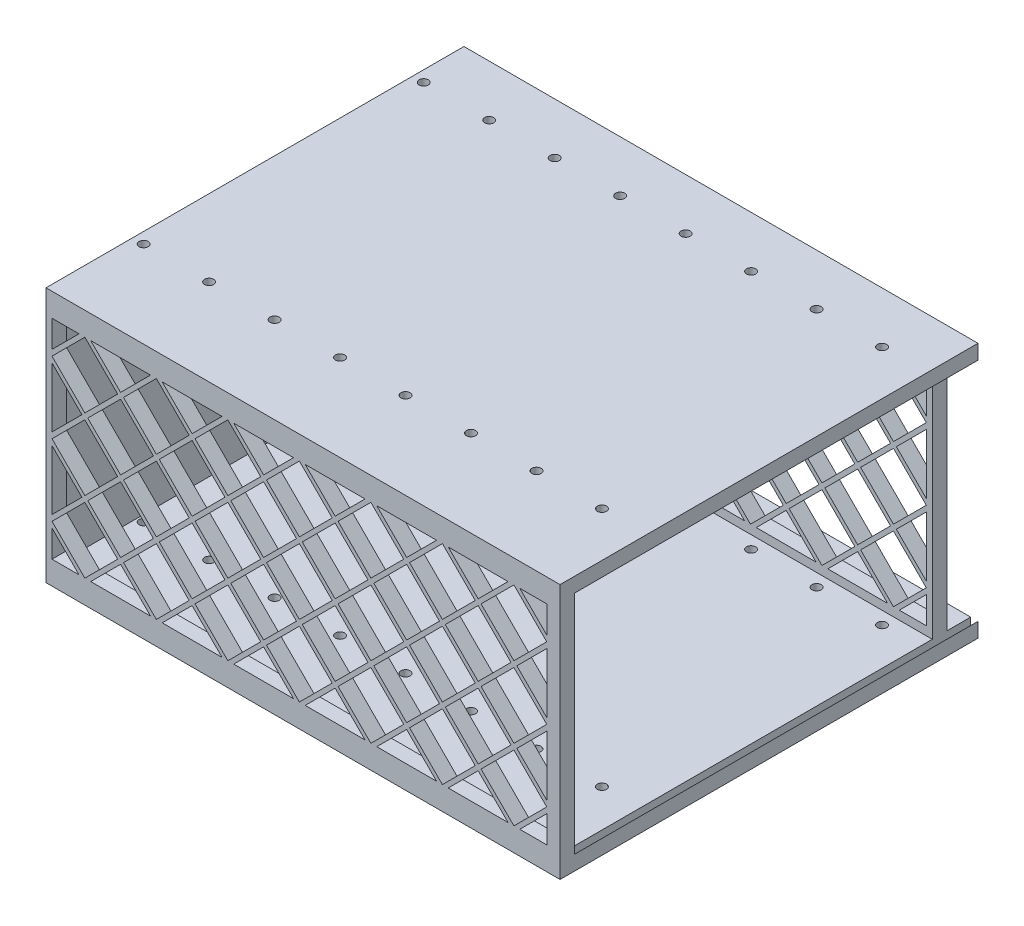
from build123d import *

# Parameters (mm, degrees)
SKETCH1_W           = 140.589
SKETCH1_H           = 114.3
BOSS_EXTRUDE1_DEPTH = 69.85
SKETCH4_W           = 6.5
SKETCH4_H           = 61.85
CUT_EXTRUDE2_DEPTH  = 141.589
SKETCH3_W           = 99.8
SKETCH3_H           = 61.85
CUT_EXTRUDE3_DEPTH  = 139.389
SKETCH2_R           = 1.25
CUT_EXTRUDE1_DEPTH  = 4
CUT_EXTRUDE4_DEPTH  = 110.3
CUT_EXTRUDE5_DEPTH  = 4


with BuildPart() as part:
    # Sketch1 → Boss-Extrude1 (new body)
    with BuildSketch(Plane(origin=(0, 0, 0), x_dir=(1, 0, 0), z_dir=(0, 1, 0))):
        with Locations((70.2945, 57.15)):
            Rectangle(SKETCH1_W, SKETCH1_H)
    extrude(amount=BOSS_EXTRUDE1_DEPTH)

    # Sketch4 → Cut-Extrude2 (cut, through all)
    with BuildSketch(Plane(origin=(140.589, 0, 0), x_dir=(0, 0, -1), z_dir=(1, 0, 0))):
        with Locations((111.05, 34.925)):
            Rectangle(SKETCH4_W, SKETCH4_H)
    extrude(amount=-CUT_EXTRUDE2_DEPTH, mode=Mode.SUBTRACT)

    # Sketch3 → Cut-Extrude3 (cut)
    with BuildSketch(Plane(origin=(140.589, 0, 0), x_dir=(0, 0, -1), z_dir=(1, 0, 0))):
        with Locations((53.9, 34.925)):
            Rectangle(SKETCH3_W, SKETCH3_H)
    extrude(amount=-CUT_EXTRUDE3_DEPTH, mode=Mode.SUBTRACT)

    # Sketch2 → Cut-Extrude1 (cut)
    with BuildSketch(Plane(origin=(0, 69.85, 0), x_dir=(1, 0, 0), z_dir=(0, 1, 0))):
        with Locations((3, 100.3)):
            Circle(SKETCH2_R)
        with Locations((3, 23.7)):
            Circle(SKETCH2_R)
        with Locations((20.907, 100.3)):
            Circle(SKETCH2_R)
        with Locations((20.907, 23.7)):
            Circle(SKETCH2_R)
        with Locations((38.814, 100.3)):
            Circle(SKETCH2_R)
        with Locations((38.814, 23.7)):
            Circle(SKETCH2_R)
        with Locations((56.721, 100.3)):
            Circle(SKETCH2_R)
        with Locations((56.721, 23.7)):
            Circle(SKETCH2_R)
        with Locations((74.628, 100.3)):
            Circle(SKETCH2_R)
        with Locations((74.628, 23.7)):
            Circle(SKETCH2_R)
        with Locations((92.535, 100.3)):
            Circle(SKETCH2_R)
        with Locations((92.535, 23.7)):
            Circle(SKETCH2_R)
        with Locations((110.442, 100.3)):
            Circle(SKETCH2_R)
        with Locations((110.442, 23.7)):
            Circle(SKETCH2_R)
        with Locations((128.349, 100.3)):
            Circle(SKETCH2_R)
        with Locations((128.349, 23.7)):
            Circle(SKETCH2_R)
    cut_extrude1 = extrude(amount=-CUT_EXTRUDE1_DEPTH, mode=Mode.SUBTRACT)

    # Mirror1: Cut-Extrude1 across plane
    add(cut_extrude1.mirror(Plane.ZX.offset(34.925)), mode=Mode.SUBTRACT)

    # Sketch5 → Cut-Extrude4 (cut)
    with BuildSketch(Plane(origin=(0, 0, -114.3), x_dir=(-1, 0, 0), z_dir=(0, 0, -1))):
        Polygon((-138.589, 67.85), (-138.589, 2), (-140.589, 4), (-140.589, 65.85), align=None)
    extrude(amount=-CUT_EXTRUDE4_DEPTH, mode=Mode.SUBTRACT)

    # Sketch6 → Cut-Extrude5 (cut)
    with BuildSketch(Plane(origin=(0, 0, -107.8), x_dir=(-1, 0, 0), z_dir=(0, 0, -1))):
        Polygon((-136.948756121, 54.483), (-127.9685, 45.502743879), (-118.988243879, 54.483), (-127.9685, 63.463256121), align=None)
        Polygon((-108.4105, 63.463256121), (-117.390756121, 54.483), (-108.4105, 45.502743879), (-99.430243879, 54.483), align=None)
        Polygon((-88.8525, 63.463256121), (-97.832756121, 54.483), (-88.8525, 45.502743879), (-79.872243879, 54.483), align=None)
        Polygon((-69.2945, 63.463256121), (-78.274756121, 54.483), (-69.2945, 45.502743879), (-60.314243879, 54.483), align=None)
        Polygon((-49.7365, 63.463256121), (-58.716756121, 54.483), (-49.7365, 45.502743879), (-40.756243879, 54.483), align=None)
        Polygon((-30.1785, 63.463256121), (-39.158756121, 54.483), (-30.1785, 45.502743879), (-21.198243879, 54.483), align=None)
        Polygon((-10.6205, 63.463256121), (-19.600756121, 54.483), (-10.6205, 45.502743879), (-1.640243879, 54.483), align=None)
        Polygon((-108.4105, 43.905256121), (-117.390756121, 34.925), (-108.4105, 25.944743879), (-99.430243879, 34.925), align=None)
        Polygon((-88.8525, 43.905256121), (-97.832756121, 34.925), (-88.8525, 25.944743879), (-79.872243879, 34.925), align=None)
        Polygon((-69.2945, 43.905256121), (-78.274756121, 34.925), (-69.2945, 25.944743879), (-60.314243879, 34.925), align=None)
        Polygon((-49.7365, 43.905256121), (-58.716756121, 34.925), (-49.7365, 25.944743879), (-40.756243879, 34.925), align=None)
        Polygon((-30.1785, 43.905256121), (-39.158756121, 34.925), (-30.1785, 25.944743879), (-21.198243879, 34.925), align=None)
        Polygon((-10.6205, 43.905256121), (-19.600756121, 34.925), (-10.6205, 25.944743879), (-1.640243879, 34.925), align=None)
        Polygon((-108.4105, 24.347256121), (-117.390756121, 15.367), (-108.4105, 6.386743879), (-99.430243879, 15.367), align=None)
        Polygon((-88.8525, 24.347256121), (-97.832756121, 15.367), (-88.8525, 6.386743879), (-79.872243879, 15.367), align=None)
        Polygon((-69.2945, 24.347256121), (-78.274756121, 15.367), (-69.2945, 6.386743879), (-60.314243879, 15.367), align=None)
        Polygon((-49.7365, 24.347256121), (-58.716756121, 15.367), (-49.7365, 6.386743879), (-40.756243879, 15.367), align=None)
        Polygon((-30.1785, 24.347256121), (-39.158756121, 15.367), (-30.1785, 6.386743879), (-21.198243879, 15.367), align=None)
        Polygon((-10.6205, 24.347256121), (-19.600756121, 15.367), (-10.6205, 6.386743879), (-1.640243879, 15.367), align=None)
        Polygon((-127.9685, 43.905256121), (-136.948756121, 34.925), (-127.9685, 25.944743879), (-118.988243879, 34.925), align=None)
        Polygon((-127.9685, 24.347256121), (-136.948756121, 15.367), (-127.9685, 6.386743879), (-118.988243879, 15.367), align=None)
        Polygon((-127.169756121, 44.704), (-118.1895, 35.723743879), (-109.209243879, 44.704), (-118.1895, 53.684256121), align=None)
        Polygon((-107.611756121, 44.704), (-98.6315, 35.723743879), (-89.651243879, 44.704), (-98.6315, 53.684256121), align=None)
        Polygon((-88.053756121, 44.704), (-79.0735, 35.723743879), (-70.093243879, 44.704), (-79.0735, 53.684256121), align=None)
        Polygon((-68.495756121, 44.704), (-59.5155, 35.723743879), (-50.535243879, 44.704), (-59.5155, 53.684256121), align=None)
        Polygon((-48.937756121, 44.704), (-39.9575, 35.723743879), (-30.977243879, 44.704), (-39.9575, 53.684256121), align=None)
        Polygon((-29.379756121, 44.704), (-20.3995, 35.723743879), (-11.419243879, 44.704), (-20.3995, 53.684256121), align=None)
        Polygon((-107.611756121, 25.146), (-98.6315, 16.165743879), (-89.651243879, 25.146), (-98.6315, 34.126256121), align=None)
        Polygon((-88.053756121, 25.146), (-79.0735, 16.165743879), (-70.093243879, 25.146), (-79.0735, 34.126256121), align=None)
        Polygon((-68.495756121, 25.146), (-59.5155, 16.165743879), (-50.535243879, 25.146), (-59.5155, 34.126256121), align=None)
        Polygon((-48.937756121, 25.146), (-39.9575, 16.165743879), (-30.977243879, 25.146), (-39.9575, 34.126256121), align=None)
        Polygon((-29.379756121, 25.146), (-20.3995, 16.165743879), (-11.419243879, 25.146), (-20.3995, 34.126256121), align=None)
        Polygon((-127.169756121, 25.146), (-118.1895, 16.165743879), (-109.209243879, 25.146), (-118.1895, 34.126256121), align=None)
        Polygon((-136.948756121, 52.885512242), (-136.948756121, 36.522487758), (-128.767243879, 44.704), align=None)
        Polygon((-128.767243879, 25.146), (-136.948756121, 33.327512242), (-136.948756121, 16.964487758), align=None)
        Polygon((-136.948756121, 56.080487758), (-136.948756121, 63.463256121), (-129.565987758, 63.463256121), align=None)
        Polygon((-136.948756121, 13.769512242), (-136.948756121, 6.386743879), (-129.565987758, 6.386743879), align=None)
        Polygon((-1.640243879, 6.386743879), (-9.023012242, 6.386743879), (-1.640243879, 13.769512242), align=None)
        Polygon((-1.640243879, 16.964487758), (-9.821756121, 25.146), (-1.640243879, 33.327512242), align=None)
        Polygon((-1.640243879, 36.522487758), (-9.821756121, 44.704), (-1.640243879, 52.885512242), align=None)
        Polygon((-1.640243879, 63.463256121), (-9.023012242, 63.463256121), (-1.640243879, 56.080487758), align=None)
        Polygon((-126.371012242, 6.386743879), (-110.007987758, 6.386743879), (-118.1895, 14.568256121), align=None)
        Polygon((-98.6315, 14.568256121), (-106.813012242, 6.386743879), (-90.449987758, 6.386743879), align=None)
        Polygon((-79.0735, 14.568256121), (-87.255012242, 6.386743879), (-70.891987758, 6.386743879), align=None)
        Polygon((-59.5155, 14.568256121), (-67.697012242, 6.386743879), (-51.333987758, 6.386743879), align=None)
        Polygon((-39.9575, 14.568256121), (-48.139012242, 6.386743879), (-31.775987758, 6.386743879), align=None)
        Polygon((-20.3995, 14.568256121), (-28.581012242, 6.386743879), (-12.217987758, 6.386743879), align=None)
        Polygon((-12.217987758, 63.463256121), (-20.3995, 55.281743879), (-28.581012242, 63.463256121), align=None)
        Polygon((-31.775987758, 63.463256121), (-39.9575, 55.281743879), (-48.139012242, 63.463256121), align=None)
        Polygon((-51.333987758, 63.463256121), (-59.5155, 55.281743879), (-67.697012242, 63.463256121), align=None)
        Polygon((-70.891987758, 63.463256121), (-79.0735, 55.281743879), (-87.255012242, 63.463256121), align=None)
        Polygon((-90.449987758, 63.463256121), (-98.6315, 55.281743879), (-106.813012242, 63.463256121), align=None)
        Polygon((-110.007987758, 63.463256121), (-118.1895, 55.281743879), (-126.371012242, 63.463256121), align=None)
    cut_extrude5 = extrude(amount=-CUT_EXTRUDE5_DEPTH, mode=Mode.SUBTRACT)

    # Mirror2: Cut-Extrude5 across plane
    add(cut_extrude5.mirror(Plane.XY.offset(-53.9)), mode=Mode.SUBTRACT)


solid = part.part
